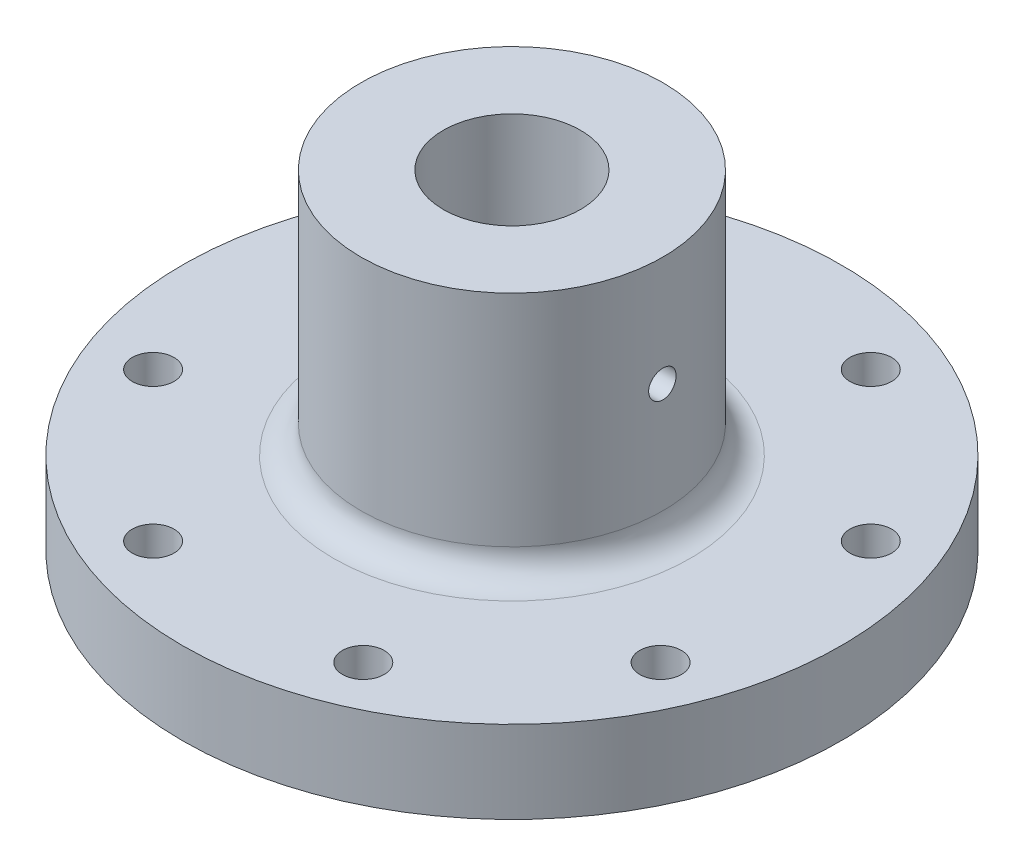
from build123d import *

# Parameters (mm, degrees)
SKETCH1_R               = 38.1
SKETCH1_R_2             = 7.9375
BOSS_EXTRUDE1_DEPTH     = 38.1
F_10_32_TAPPED_HOLE1_D  = 4.826
CIRPATTERN1_COUNT       = 8
SKETCH7_OUTSIDE_W       = 101.06
SKETCH7_OUTSIDE_H       = 101.06
SKETCH7_OUTSIDE_R       = 17.4625
CUT_EXTRUDE2_DEPTH      = 28.575
FILLET1_R               = 3.175
SKETCH8_R               = 1.5875
CUT_EXTRUDE3_DEPTH      = 39.1
CUT_EXTRUDE3_DEPTH_BACK = 39.1


with BuildPart() as part:
    # Sketch1 → Boss-Extrude1 (new body)
    with BuildSketch(Plane(origin=(0, 0, 0), x_dir=(1, 0, 0), z_dir=(0, 1, 0))):
        with Locations(Location((0, 0, 0), (0, 0, 270))):  # turned: the seam where the file's is
            Circle(SKETCH1_R)
        with Locations(Location((0, 0, 0), (0, 0, 270))):  # turned: the seam where the file's is
            Circle(SKETCH1_R_2, mode=Mode.SUBTRACT)
    extrude(amount=BOSS_EXTRUDE1_DEPTH)

    # #10-32 Tapped Hole1 (through all)
    with Locations(Plane(origin=(0, 38.1, 0), x_dir=(-1, 0, 0), z_dir=(0, 1, 0))):
        with Locations((29.333175157, -12.150198978)):
            f_10_32_tapped_hole1 = Hole(F_10_32_TAPPED_HOLE1_D / 2)

    # CirPattern1: #10-32 Tapped Hole1 ×8 about axis
    cirpattern1_axis = Axis((0, 0, 0), (0, 1, 0))
    for i in range(1, CIRPATTERN1_COUNT):
        add(f_10_32_tapped_hole1.rotate(cirpattern1_axis, i * 360 / CIRPATTERN1_COUNT), mode=Mode.SUBTRACT)

    # Sketch7 outside → Cut-Extrude2 (cut)
    with BuildSketch(Plane(origin=(0, 38.1, 0), x_dir=(1, 0, 0), z_dir=(0, 1, 0))):
        Rectangle(SKETCH7_OUTSIDE_W, SKETCH7_OUTSIDE_H)
        with Locations(Location((0, 0, 0), (0, 0, 270))):  # turned: the seam where the file's is
            Circle(SKETCH7_OUTSIDE_R, mode=Mode.SUBTRACT)
    extrude(amount=-CUT_EXTRUDE2_DEPTH, mode=Mode.SUBTRACT)

    # Fillet1
    fillet1_edges = [part.edges().sort_by_distance(p)[0] for p in [
        (0, 9.525, -17.4625),
    ]]
    fillet(fillet1_edges, radius=FILLET1_R)

    # Sketch8 → Cut-Extrude3 (cut, two sides)
    with BuildSketch(Plane(origin=(0, 0, 0), x_dir=(0, 0, -1), z_dir=(1, 0, 0))) as cut_extrude3_sk:
        with Locations((0, 25.4)):
            Circle(SKETCH8_R)
    extrude(amount=CUT_EXTRUDE3_DEPTH, mode=Mode.SUBTRACT)
    extrude(cut_extrude3_sk.sketch, amount=-CUT_EXTRUDE3_DEPTH_BACK, mode=Mode.SUBTRACT)


solid = part.part
